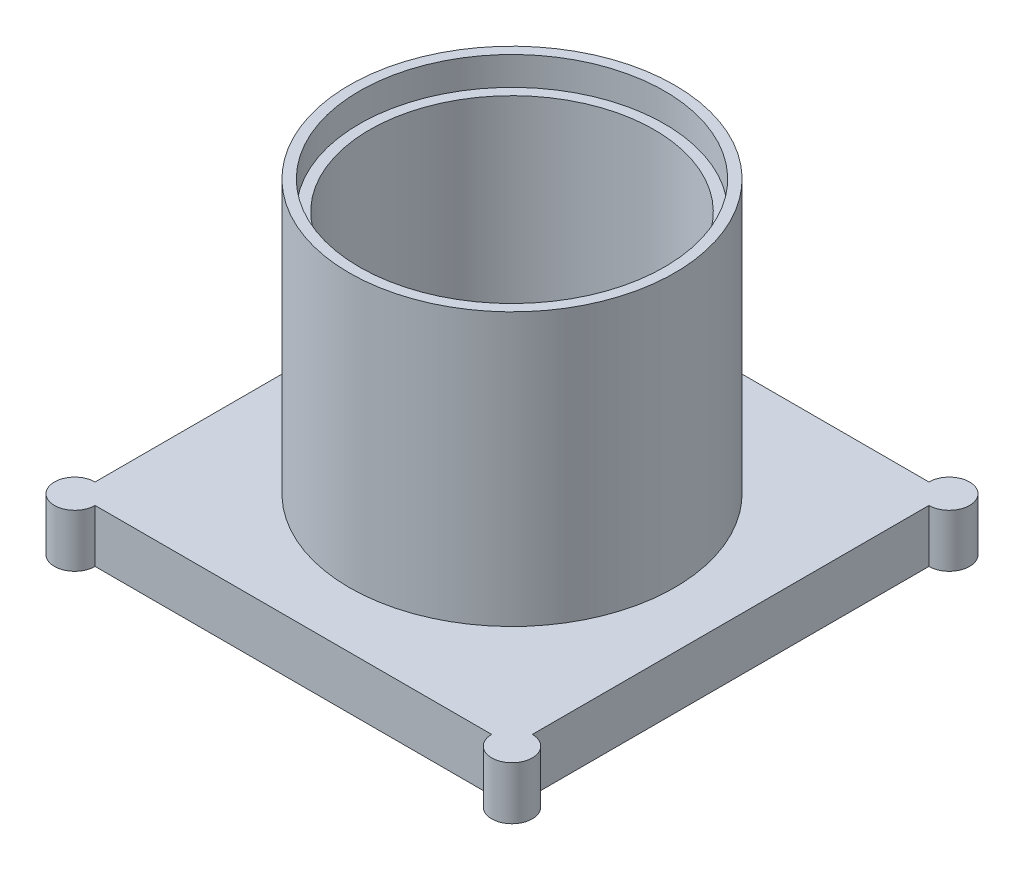
from build123d import *

# Parameters (mm, degrees)
IZIM1_R                     = 80
Y_KSEKLIK_EKSTR_ZYON1_DEPTH = 26
IZIM1_7_R                   = 80
IZIM1_7_R_2                 = 75
Y_KSEKLIK_EKSTR_ZYON2_DEPTH = 160
IZIM1_9_R                   = 75
IZIM1_9_R_2                 = 70
Y_KSEKLIK_EKSTR_ZYON3_DEPTH = 146


with BuildPart() as part:
    # Çizim1 → Yükseklik-Ekstrüzyon1 (new body)
    with BuildSketch(Plane(origin=(0, 0, 0), x_dir=(1, 0, 0), z_dir=(0, 1, 0))):
        with BuildLine():
            Line((98.086576189, 75.169734496), (-96.913423811, 75.169734496))
            ThreePointArc((-96.913423811, 75.169734496), (-113.984491623, 82.240802308), (-106.913423811, 65.169734496))
            Line((-106.913423811, 65.169734496), (-106.913423811, -129.830265504))
            ThreePointArc((-106.913423811, -129.830265504), (-113.984491623, -146.901333316), (-96.913423811, -139.830265504))
            Line((-96.913423811, -139.830265504), (98.086576189, -139.830265504))
            ThreePointArc((98.086576189, -139.830265504), (115.157644, -146.901333316), (108.086576189, -129.830265504))
            Line((108.086576189, -129.830265504), (108.086576189, 65.169734496))
            ThreePointArc((108.086576189, 65.169734496), (115.157644, 82.240802308), (98.086576189, 75.169734496))
        make_face()
        with Locations((0.586576189, -32.330265504)):
            Circle(IZIM1_R, mode=Mode.SUBTRACT)
    extrude(amount=Y_KSEKLIK_EKSTR_ZYON1_DEPTH)

    # Çizim1<7> → Yükseklik-Ekstrüzyon2 (add)
    with BuildSketch(Plane(origin=(0, 0, 0), x_dir=(1, 0, 0), z_dir=(0, 1, 0))):
        with Locations((0.586576189, -32.330265504)):
            Circle(IZIM1_7_R)
        with Locations((0.586576189, -32.330265504)):
            Circle(IZIM1_7_R_2, mode=Mode.SUBTRACT)
    extrude(amount=Y_KSEKLIK_EKSTR_ZYON2_DEPTH)

    # Çizim1<9> → Yükseklik-Ekstrüzyon3 (add)
    with BuildSketch(Plane(origin=(0, 0, 0), x_dir=(1, 0, 0), z_dir=(0, 1, 0))):
        with Locations((0.586576189, -32.330265504)):
            Circle(IZIM1_9_R)
        with Locations((0.586576189, -32.330265504)):
            Circle(IZIM1_9_R_2, mode=Mode.SUBTRACT)
    extrude(amount=Y_KSEKLIK_EKSTR_ZYON3_DEPTH)


solid = part.part
